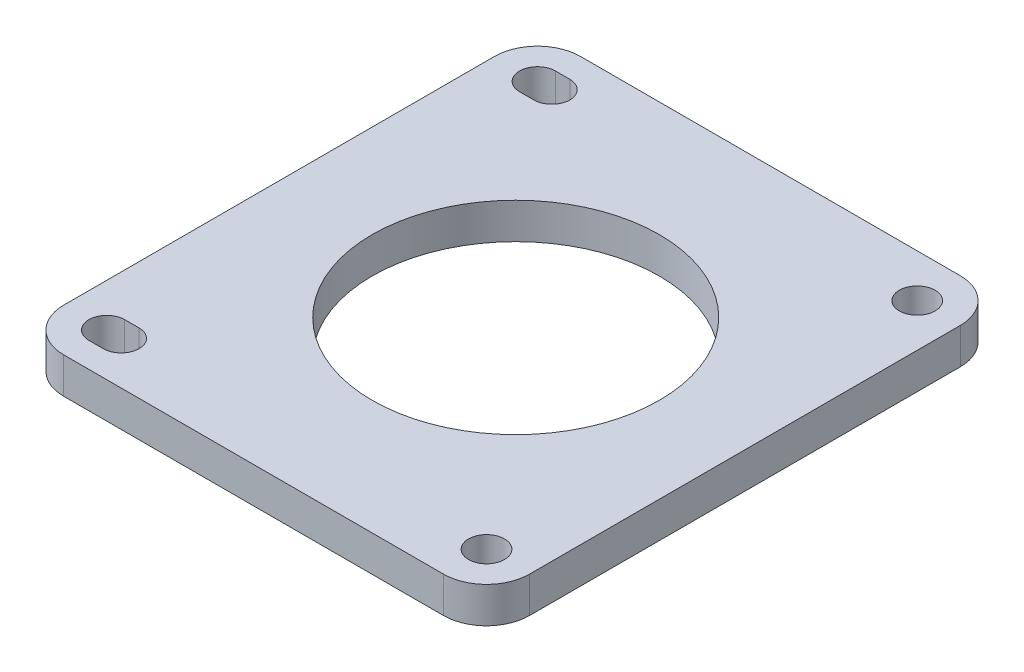
from build123d import *

# Parameters (mm, degrees)
SKETCH1_R           = 2.5
SKETCH1_R_2         = 20
BOSS_EXTRUDE1_DEPTH = 5


with BuildPart() as part:
    # Sketch1 → Boss-Extrude1 (new body)
    with BuildSketch(Plane(origin=(0, 0, 0), x_dir=(1, 0, 0), z_dir=(0, 1, 0))):
        with BuildLine():
            Line((6, 0), (58.9, 0))
            ThreePointArc((58.9, 0), (63.142640687, 1.757359313), (64.9, 6))
            Line((64.9, 6), (64.9, 66))
            ThreePointArc((64.9, 66), (63.142640687, 70.242640687), (58.9, 72))
            Line((58.9, 72), (6, 72))
            ThreePointArc((6, 72), (1.757359313, 70.242640687), (0, 66))
            Line((0, 66), (0, 6))
            ThreePointArc((0, 6), (1.757359313, 1.757359313), (6, 0))
        make_face()
        with Locations((58.9, 66)):
            Circle(SKETCH1_R, mode=Mode.SUBTRACT)
        with Locations((58.9, 6)):
            Circle(SKETCH1_R, mode=Mode.SUBTRACT)
        with Locations((32.97, 36)):
            Circle(SKETCH1_R_2, mode=Mode.SUBTRACT)
        with BuildLine():
            Line((6, 3.5), (8, 3.5))
            ThreePointArc((8, 3.5), (10.5, 6), (8, 8.5))
            Line((8, 8.5), (6, 8.5))
            ThreePointArc((6, 8.5), (3.5, 6), (6, 3.5))
        make_face(mode=Mode.SUBTRACT)
        with BuildLine():
            Line((6, 63.5), (8, 63.5))
            ThreePointArc((8, 63.5), (10.5, 66), (8, 68.5))
            Line((8, 68.5), (6, 68.5))
            ThreePointArc((6, 68.5), (3.5, 66), (6, 63.5))
        make_face(mode=Mode.SUBTRACT)
    extrude(amount=BOSS_EXTRUDE1_DEPTH)


solid = part.part
